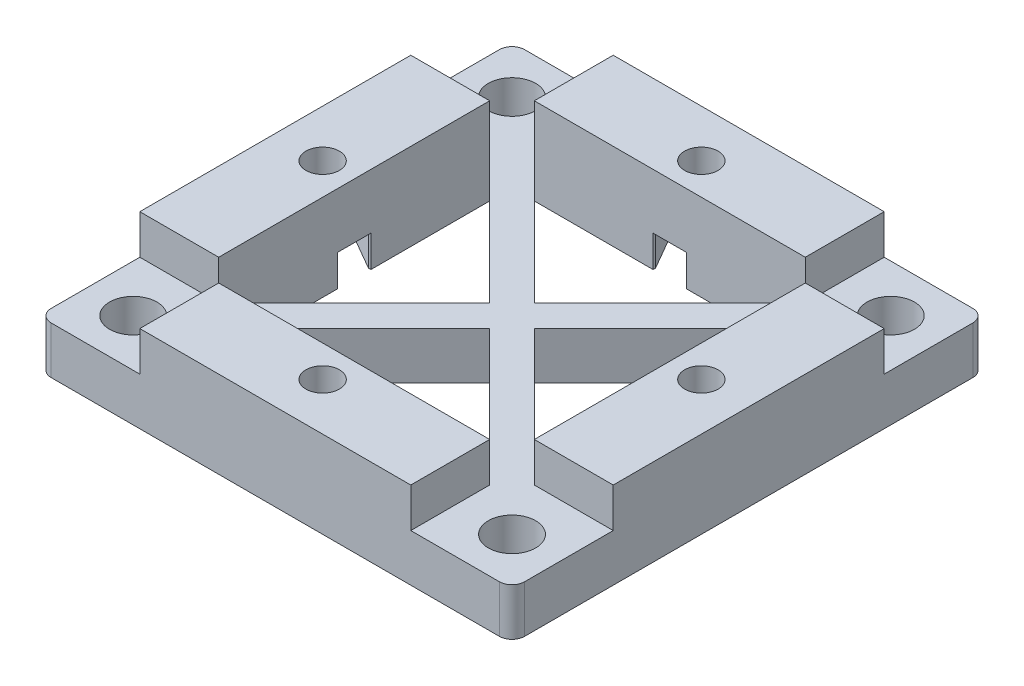
from build123d import *

# Parameters (mm, degrees)
SKETCH1_W           = 95.25
SKETCH1_H           = 95.25
SKETCH1_R           = 4.7625
BOSS_EXTRUDE1_DEPTH = 9.525
FILLET1_R           = 2.54
SKETCH3_W           = 54.519743878
SKETCH3_H           = 15.875
SKETCH3_W_2         = 15.875
SKETCH3_H_2         = 54.519743878
BOSS_EXTRUDE3_DEPTH = 7.9375
SKETCH4_R           = 3.3734375
CUT_EXTRUDE1_DEPTH  = 18.4625
SKETCH5_R           = 3.3734375
SKETCH5_W           = 0.508
SKETCH5_H           = 6.745760546
SKETCH5_W_2         = 6.745760546
SKETCH5_H_2         = 0.508
CUT_EXTRUDE2_DEPTH  = 6.35


with BuildPart() as part:
    # Sketch1 → Boss-Extrude1 (new body)
    with BuildSketch(Plane(origin=(0, 0, 0), x_dir=(1, 0, 0), z_dir=(0, 1, 0))):
        with Locations((47.625, -47.625)):
            Rectangle(SKETCH1_W, SKETCH1_H)
        with Locations((9.525, -85.725)):
            Circle(SKETCH1_R, mode=Mode.SUBTRACT)
        Polygon((15.875, -74.884871939), (15.875, -20.365128061), (43.134871939, -47.625), align=None, mode=Mode.SUBTRACT)
        with Locations((85.725, -85.725)):
            Circle(SKETCH1_R, mode=Mode.SUBTRACT)
        Polygon((74.884871939, -79.375), (20.365128061, -79.375), (47.625, -52.115128061), align=None, mode=Mode.SUBTRACT)
        with Locations((9.525, -9.525)):
            Circle(SKETCH1_R, mode=Mode.SUBTRACT)
        Polygon((52.115128061, -47.625), (79.375, -20.365128061), (79.375, -74.884871939), align=None, mode=Mode.SUBTRACT)
        Polygon((47.625, -43.134871939), (20.365128061, -15.875), (74.884871939, -15.875), align=None, mode=Mode.SUBTRACT)
        with Locations((85.725, -9.525)):
            Circle(SKETCH1_R, mode=Mode.SUBTRACT)
    extrude(amount=BOSS_EXTRUDE1_DEPTH)

    # Fillet1
    fillet1_edges = [part.edges().sort_by_distance(p)[0] for p in [
        (95.25, 4.7625, 95.25),
        (0, 4.7625, 95.25),
        (0, 4.7625, 0),
        (95.25, 4.7625, 0),
    ]]
    fillet(fillet1_edges, radius=FILLET1_R)

    # Sketch3 → Boss-Extrude3 (add)
    with BuildSketch(Plane(origin=(0, 9.525, 0), x_dir=(1, 0, 0), z_dir=(0, 1, 0))):
        with Locations((47.625, -7.9375)):
            Rectangle(SKETCH3_W, SKETCH3_H)
        with Locations((87.3125, -47.625)):
            Rectangle(SKETCH3_W_2, SKETCH3_H_2)
        with Locations((47.625, -87.3125)):
            Rectangle(SKETCH3_W, SKETCH3_H)
        with Locations((7.9375, -47.625)):
            Rectangle(SKETCH3_W_2, SKETCH3_H_2)
    extrude(amount=BOSS_EXTRUDE3_DEPTH)

    # Sketch4 → Cut-Extrude1 (cut, through all)
    with BuildSketch(Plane(origin=(0, 17.4625, 0), x_dir=(1, 0, 0), z_dir=(0, 1, 0))):
        with Locations((85.725, -47.625)):
            Circle(SKETCH4_R)
        with Locations((47.625, -85.725)):
            Circle(SKETCH4_R)
        with Locations((9.525, -47.625)):
            Circle(SKETCH4_R)
        with Locations((47.625, -9.525)):
            Circle(SKETCH4_R)
    extrude(amount=-CUT_EXTRUDE1_DEPTH, mode=Mode.SUBTRACT)

    # Sketch5 → Cut-Extrude2 (cut)
    with BuildSketch(Plane.XZ):
        Polygon((85.725, 54.370760545), (79.883, 50.997880273), (79.883, 44.252119727), (85.725, 40.879239455), (91.567, 44.252119727), (91.567, 50.997880273), align=None)
        with Locations((85.725, 47.625)):
            Circle(SKETCH5_R, mode=Mode.SUBTRACT)
        with Locations((79.629, 47.625)):
            Rectangle(SKETCH5_W, SKETCH5_H)
        Polygon((50.997880273, 91.567), (44.252119727, 91.567), (40.879239455, 85.725), (44.252119727, 79.883), (50.997880273, 79.883), (54.370760545, 85.725), align=None)
        with Locations((47.625, 85.725)):
            Circle(SKETCH5_R, mode=Mode.SUBTRACT)
        with Locations((47.625, 79.629)):
            Rectangle(SKETCH5_W_2, SKETCH5_H_2)
        Polygon((15.367, 44.252119727), (15.367, 50.997880273), (9.525, 54.370760545), (3.683, 50.997880273), (3.683, 44.252119727), (9.525, 40.879239455), align=None)
        with Locations((9.525, 47.625)):
            Circle(SKETCH5_R, mode=Mode.SUBTRACT)
        with Locations((15.621, 47.625)):
            Rectangle(SKETCH5_W, SKETCH5_H)
        Polygon((50.997880273, 15.367), (44.252119727, 15.367), (40.879239455, 9.525), (44.252119727, 3.683), (50.997880273, 3.683), (54.370760545, 9.525), align=None)
        with Locations((47.625, 9.525)):
            Circle(SKETCH5_R, mode=Mode.SUBTRACT)
        with Locations((47.625, 15.621)):
            Rectangle(SKETCH5_W_2, SKETCH5_H_2)
    extrude(amount=-CUT_EXTRUDE2_DEPTH, mode=Mode.SUBTRACT)


solid = part.part
